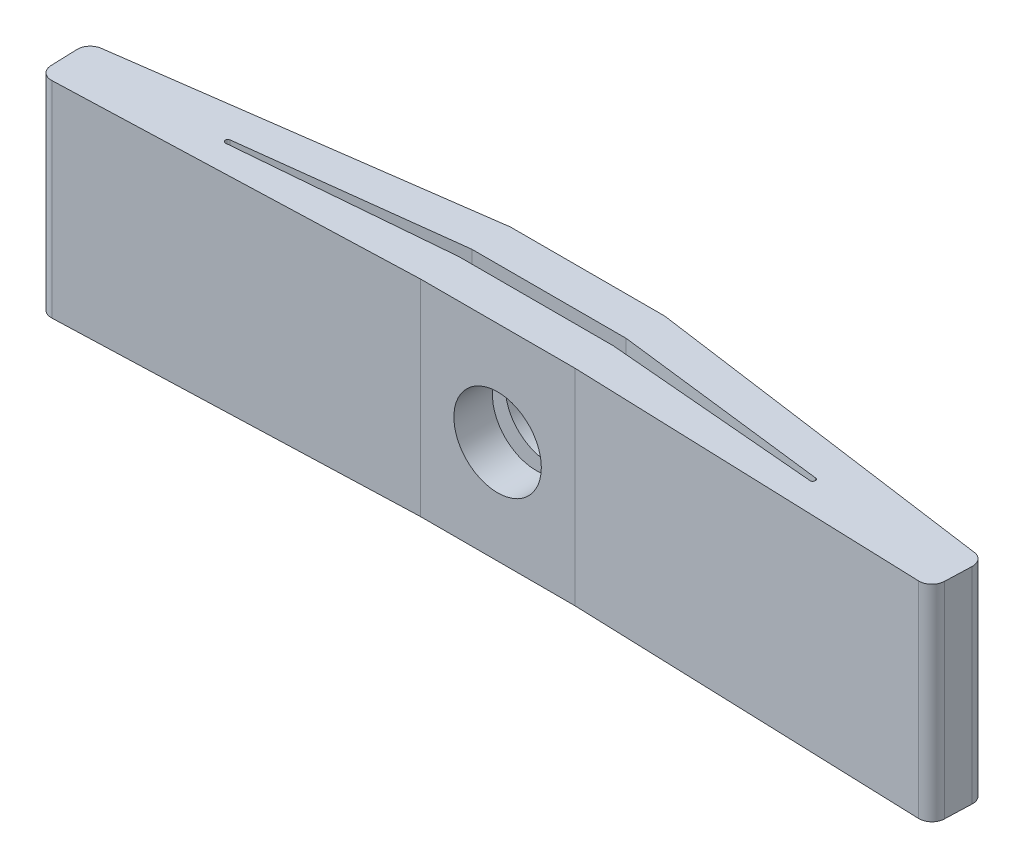
from build123d import *

# Parameters (mm, degrees)
BOSS_EXTRUDE1_DEPTH  = 8
CUT_EXTRUDE1_DEPTH   = 9
M3_CLEARANCE_HOLE1_D = 3.4
FILLET1_R            = 0.5


with BuildPart() as part:
    # Sketch1 → Boss-Extrude1 (new body)
    with BuildSketch(Plane(origin=(0, 8, 0), x_dir=(1, 0, 0), z_dir=(0, 1, 0))):
        Polygon((34.769686411, 2), (20.35, 4), (14.35, 4), (-0.069686411, 2), (0, 0), (14.35, 0.5), (20.35, 0.5), (34.7, 0), align=None)
    extrude(amount=-BOSS_EXTRUDE1_DEPTH)

    # Sketch2 → Cut-Extrude1 (cut, through all)
    with BuildSketch(Plane.XZ):
        with BuildLine():
            Line((5.968779898, -1.482280416), (14.35, -2.5))
            Line((14.35, -2.5), (20.35, -2.5))
            Line((20.35, -2.5), (28.731220102, -1.482280416))
            ThreePointArc((28.731220102, -1.482280416), (28.818634048, -1.372710787), (28.710625676, -1.283374942))
            Line((28.710625676, -1.283374942), (20.35, -2))
            Line((20.35, -2), (14.35, -2))
            Line((14.35, -2), (5.989374324, -1.283374942))
            ThreePointArc((5.989374324, -1.283374942), (5.881365952, -1.372710787), (5.968779898, -1.482280416))
        make_face()
    extrude(amount=-CUT_EXTRUDE1_DEPTH, mode=Mode.SUBTRACT)

    # M3 Clearance Hole1 (through all)
    with Locations(Plane.XY.offset(-0.5)):
        with Locations((17.35, 4)):
            Hole(M3_CLEARANCE_HOLE1_D / 2)

    # Fillet1
    fillet1_edges = [part.edges().sort_by_distance(p)[0] for p in [
        (34.7, 4, 0),
        (0, 4, 0),
        (-0.069686411, 4, -2),
        (34.769686411, 4, -2),
    ]]
    fillet(fillet1_edges, radius=FILLET1_R)


solid = part.part
